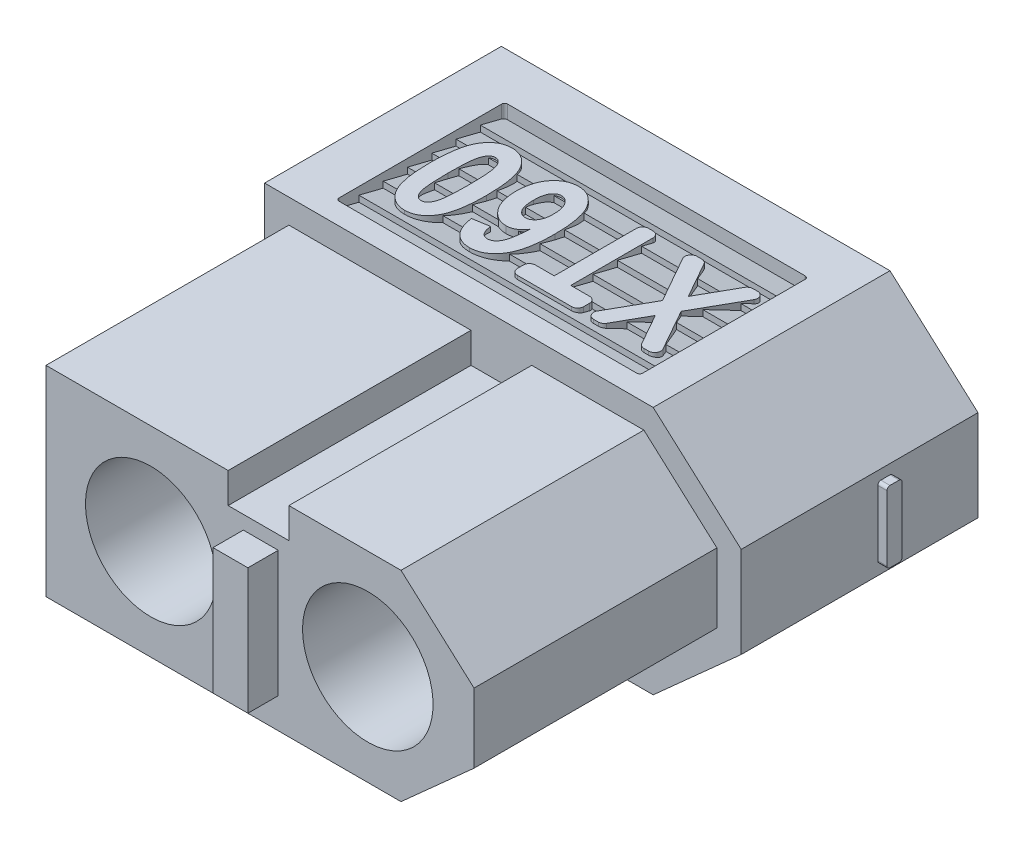
from build123d import *

# Parameters (mm, degrees)
RESSALTO_EXTRUS_O1_DEPTH  = 15.8
CORTE_EXTRUS_O1_DEPTH     = 8
ESBO_O5_R                 = 3
CORTE_EXTRUS_O3_DEPTH     = 2
ESBO_O6_R                 = 2.15
CORTE_EXTRUS_O4_DEPTH     = 14.8
RESSALTO_EXTRUS_O3_DEPTH  = 0.3
RESSALTO_EXTRUS_O4_DEPTH  = 0.3
CORTE_EXTRUS_O5_DEPTH     = 0.75
RESSALTO_EXTRUS_O7_DEPTH  = 10
RESSALTO_EXTRUS_O8_DEPTH  = 0.3
RESSALTO_EXTRUS_O9_DEPTH  = 0.3
ESBO_O13_W                = 1.15
ESBO_O13_H                = 4.15
RESSALTO_EXTRUS_O10_DEPTH = 1


with BuildPart() as part:
    # Esboço1 → Ressalto-extrusão1 (new body)
    with BuildSketch(Plane.XY):
        Polygon((0, 0), (12.8, 0), (15.7, 2.6), (15.7, 5.6), (12.8, 8.2), (0, 8.2), align=None)
    extrude(amount=RESSALTO_EXTRUS_O1_DEPTH)

    # Esboço2 → Corte-extrusão1 (cut)
    with BuildSketch(Plane.XY.offset(15.8)):
        Polygon((0, 8.2), (0, 0), (12.8, 0), (15.7, 2.6), (15.7, 5.6), (12.8, 8.2), align=None)
        Polygon((0.8, 7.4), (0.8, 0.8), (12.49388664, 0.8), (14.9, 2.957205081), (14.9, 5.242794919), (12.49388664, 7.4), (8.8, 7.4), (8.8, 6.4), (6.8, 6.4), (6.8, 7.4), align=None, mode=Mode.SUBTRACT)
    extrude(amount=-CORTE_EXTRUS_O1_DEPTH, mode=Mode.SUBTRACT)

    # Esboço5 → Corte-extrusão3 (cut)
    with BuildSketch(Plane(origin=(0, 0, 0), x_dir=(-1, 0, 0), z_dir=(0, 0, -1))):
        with Locations((-11.4, 4.1)):
            Circle(ESBO_O5_R)
        with Locations((-4.25, 4.1)):
            Circle(ESBO_O5_R)
    extrude(amount=-CORTE_EXTRUS_O3_DEPTH, mode=Mode.SUBTRACT)

    # Esboço6 → Corte-extrusão4 (cut, through all)
    with BuildSketch(Plane(origin=(0, 0, 2), x_dir=(-1, 0, 0), z_dir=(0, 0, -1))):
        with Locations((-11.4, 4.1)):
            Circle(ESBO_O6_R)
        with Locations((-4.25, 4.1)):
            Circle(ESBO_O6_R)
    extrude(amount=-CORTE_EXTRUS_O4_DEPTH, mode=Mode.SUBTRACT)

    # Esboço7 → Ressalto-extrusão3 (add)
    with BuildSketch(Plane.ZY):
        with BuildLine():
            Line((2.8, 4.35), (2.05, 4.35))
            ThreePointArc((2.05, 4.35), (1.979289322, 4.320710678), (1.95, 4.25))
            Line((1.95, 4.25), (1.95, 3.95))
            ThreePointArc((1.95, 3.95), (1.979289322, 3.879289322), (2.05, 3.85))
            Line((2.05, 3.85), (2.8, 3.85))
            ThreePointArc((2.8, 3.85), (2.870710678, 3.820710678), (2.9, 3.75))
            Line((2.9, 3.75), (2.9, 3))
            ThreePointArc((2.9, 3), (2.929289322, 2.929289322), (3, 2.9))
            Line((3, 2.9), (3.3, 2.9))
            ThreePointArc((3.3, 2.9), (3.370710678, 2.929289322), (3.4, 3))
            Line((3.4, 3), (3.4, 3.75))
            ThreePointArc((3.4, 3.75), (3.429289322, 3.820710678), (3.5, 3.85))
            Line((3.5, 3.85), (4.25, 3.85))
            ThreePointArc((4.25, 3.85), (4.320710678, 3.879289322), (4.35, 3.95))
            Line((4.35, 3.95), (4.35, 4.25))
            ThreePointArc((4.35, 4.25), (4.320710678, 4.320710678), (4.25, 4.35))
            Line((4.25, 4.35), (3.5, 4.35))
            ThreePointArc((3.5, 4.35), (3.429289322, 4.379289322), (3.4, 4.45))
            Line((3.4, 4.45), (3.4, 5.2))
            ThreePointArc((3.4, 5.2), (3.370710678, 5.270710678), (3.3, 5.3))
            Line((3.3, 5.3), (3, 5.3))
            ThreePointArc((3, 5.3), (2.929289322, 5.270710678), (2.9, 5.2))
            Line((2.9, 5.2), (2.9, 4.45))
            ThreePointArc((2.9, 4.45), (2.870710678, 4.379289322), (2.8, 4.35))
        make_face()
    extrude(amount=RESSALTO_EXTRUS_O3_DEPTH)

    # Esboço8 → Ressalto-extrusão4 (add)
    with BuildSketch(Plane(origin=(15.7, 0, 0), x_dir=(0, 0, -1), z_dir=(1, 0, 0))):
        with BuildLine():
            Line((-3.2, 2.925), (-2.9, 2.925))
            ThreePointArc((-2.9, 2.925), (-2.829289322, 2.954289322), (-2.8, 3.025))
            Line((-2.8, 3.025), (-2.8, 5.175))
            ThreePointArc((-2.8, 5.175), (-2.829289322, 5.245710678), (-2.9, 5.275))
            Line((-2.9, 5.275), (-3.2, 5.275))
            ThreePointArc((-3.2, 5.275), (-3.270710678, 5.245710678), (-3.3, 5.175))
            Line((-3.3, 5.175), (-3.3, 3.025))
            ThreePointArc((-3.3, 3.025), (-3.270710678, 2.954289322), (-3.2, 2.925))
        make_face()
    extrude(amount=RESSALTO_EXTRUS_O4_DEPTH)

    # Esboço9 → Corte-extrusão5 (cut)
    with BuildSketch(Plane.XZ):
        with BuildLine():
            Line((1.75, 7.093123445), (11.55, 7.093123445))
            ThreePointArc((11.55, 7.093123445), (11.620710678, 7.063834123), (11.65, 6.993123445))
            Line((11.65, 6.993123445), (11.65, 1.643123445))
            ThreePointArc((11.65, 1.643123445), (11.620710678, 1.572412766), (11.55, 1.543123445))
            Line((11.55, 1.543123445), (1.75, 1.543123445))
            ThreePointArc((1.75, 1.543123445), (1.679289322, 1.572412766), (1.65, 1.643123445))
            Line((1.65, 1.643123445), (1.65, 6.993123445))
            ThreePointArc((1.65, 6.993123445), (1.679289322, 7.063834123), (1.75, 7.093123445))
        make_face()
    corte_extrus_o5 = extrude(amount=-CORTE_EXTRUS_O5_DEPTH, mode=Mode.SUBTRACT)

    # Esboço10 → Ressalto-extrusão7 (add)
    with BuildSketch(Plane(origin=(1.65, 0, 0), x_dir=(0, 0, -1), z_dir=(1, 0, 0))):
        Polygon((-3.143123445, 0.45), (-3.143123445, 0.25), (-2.343123445, 0.45), (-2.343123445, 0.25), (-1.543123445, 0.45), (-1.543123445, 0.75), (-7.143123445, 0.75), (-7.143123445, 0.45), (-7.143123445, 0.25), (-6.343123445, 0.45), (-6.343123445, 0.25), (-5.543123445, 0.45), (-5.543123445, 0.25), (-4.743123445, 0.45), (-4.743123445, 0.25), (-3.943123445, 0.45), (-3.943123445, 0.25), align=None)
    ressalto_extrus_o7 = extrude(amount=RESSALTO_EXTRUS_O7_DEPTH)

    # Espelhar1: Corte-extrusão5, Ressalto-extrusão7 across plane
    add(corte_extrus_o5.mirror(Plane.ZX.offset(4.1)), mode=Mode.SUBTRACT)
    add(ressalto_extrus_o7.mirror(Plane.ZX.offset(4.1)))

    # Esboço11 → Ressalto-extrusão8 (add)
    with BuildSketch(Plane(origin=(0, 0.5, 0), x_dir=(-1, 0, 0), z_dir=(0, -1, 0))):
        with BuildLine():
            Line((-2.594171468, -5.543123445), (-2.816677367, -5.543123445))
            ThreePointArc((-2.816677367, -5.543123445), (-2.931584034, -5.489541586), (-2.96439853, -5.367076218))
            Line((-2.96439853, -5.367076218), (-2.475213344, -2.592769164))
            ThreePointArc((-2.475213344, -2.592769164), (-2.50802784, -2.470303795), (-2.622934507, -2.416721937))
            Line((-2.622934507, -2.416721937), (-2.922945856, -2.416721937))
            ThreePointArc((-2.922945856, -2.416721937), (-3.019363998, -2.45181527), (-3.070667019, -2.54067471))
            Line((-3.070667019, -2.54067471), (-3.578223521, -5.419170671))
            ThreePointArc((-3.578223521, -5.419170671), (-3.629526543, -5.508030111), (-3.725944684, -5.543123445))
            Line((-3.725944684, -5.543123445), (-4.285644183, -5.543123445))
            ThreePointArc((-4.285644183, -5.543123445), (-4.3917102, -5.587057427), (-4.435644183, -5.693123445))
            Line((-4.435644183, -5.693123445), (-4.435644183, -5.993134794))
            ThreePointArc((-4.435644183, -5.993134794), (-4.3917102, -6.099200812), (-4.285644183, -6.143134794))
            Line((-4.285644183, -6.143134794), (-2.594171468, -6.143134794))
            ThreePointArc((-2.594171468, -6.143134794), (-2.48810545, -6.099200812), (-2.444171468, -5.993134794))
            Line((-2.444171468, -5.993134794), (-2.444171468, -5.693123445))
            ThreePointArc((-2.444171468, -5.693123445), (-2.48810545, -5.587057427), (-2.594171468, -5.543123445))
        make_face()
        with BuildLine():
            Line((-7.312799939, -6.143134794), (-5.987200061, -6.143134794))
            ThreePointArc((-5.987200061, -6.143134794), (-5.912200061, -6.123038605), (-5.85729625, -6.068134794))
            Line((-5.85729625, -6.068134794), (-5.828687438, -6.018582878))
            ThreePointArc((-5.828687438, -6.018582878), (-5.681353004, -5.702623165), (-5.591122739, -5.365879233))
            Line((-5.591122739, -5.365879233), (-5.150689111, -2.868056003))
            ThreePointArc((-5.150689111, -2.868056003), (-5.158867923, -2.786982124), (-5.208226408, -2.722146896))
            Line((-5.208226408, -2.722146896), (-5.574105578, -2.446860057))
            ThreePointArc((-5.574105578, -2.446860057), (-5.616746211, -2.424455845), (-5.664289444, -2.416721937))
            Line((-5.664289444, -2.416721937), (-6.747162349, -2.416721937))
            ThreePointArc((-6.747162349, -2.416721937), (-6.822162349, -2.436818126), (-6.877066159, -2.491721937))
            Line((-6.877066159, -2.491721937), (-7.246378339, -3.131389396))
            ThreePointArc((-7.246378339, -3.131389396), (-7.254434815, -3.146865743), (-7.261111782, -3.162985367))
            Line((-7.261111782, -3.162985367), (-7.486707327, -3.782804031))
            ThreePointArc((-7.486707327, -3.782804031), (-7.491953968, -3.799444251), (-7.495730353, -3.816478424))
            Line((-7.495730353, -3.816478424), (-7.600238849, -4.409175555))
            ThreePointArc((-7.600238849, -4.409175555), (-7.567424352, -4.531640924), (-7.452517686, -4.585222782))
            Line((-7.452517686, -4.585222782), (-6.814596908, -4.585222782))
            ThreePointArc((-6.814596908, -4.585222782), (-6.708530891, -4.541288799), (-6.664596908, -4.435222782))
            Line((-6.664596908, -4.435222782), (-6.664596908, -4.135222782))
            ThreePointArc((-6.664596908, -4.135222782), (-6.688852376, -4.053440677), (-6.75377441, -3.998107415))
            ThreePointArc((-6.75377441, -3.998107415), (-6.813094, -3.957706293), (-6.85433126, -3.898964887))
            Line((-6.85433126, -3.898964887), (-6.980409874, -3.625265301))
            ThreePointArc((-6.980409874, -3.625265301), (-6.998662224, -3.535451732), (-6.974936214, -3.446926583))
            Line((-6.974936214, -3.446926583), (-6.800387282, -3.122061179))
            ThreePointArc((-6.800387282, -3.122061179), (-6.726842336, -3.045065082), (-6.624207428, -3.016721937))
            Line((-6.624207428, -3.016721937), (-5.905334252, -3.016721937))
            ThreePointArc((-5.905334252, -3.016721937), (-5.828729808, -3.052443176), (-5.806853477, -3.134086755))
            Line((-5.806853477, -3.134086755), (-6.209775425, -5.419170671))
            ThreePointArc((-6.209775425, -5.419170671), (-6.261078446, -5.508030111), (-6.357496588, -5.543123445))
            Line((-6.357496588, -5.543123445), (-7.076369764, -5.543123445))
            ThreePointArc((-7.076369764, -5.543123445), (-7.152974208, -5.507402206), (-7.174850539, -5.425758627))
            Line((-7.174850539, -5.425758627), (-7.151219061, -5.291737858))
            ThreePointArc((-7.151219061, -5.291737858), (-7.184033558, -5.16927249), (-7.298940224, -5.115690631))
            Line((-7.298940224, -5.115690631), (-7.598951574, -5.115690631))
            ThreePointArc((-7.598951574, -5.115690631), (-7.695369716, -5.150783965), (-7.746672737, -5.239643405))
            Line((-7.746672737, -5.239643405), (-7.826400273, -5.691800728))
            ThreePointArc((-7.826400273, -5.691800728), (-7.81822146, -5.772874607), (-7.768862976, -5.837709835))
            Line((-7.768862976, -5.837709835), (-7.402983805, -6.112996674))
            ThreePointArc((-7.402983805, -6.112996674), (-7.360343172, -6.135400887), (-7.312799939, -6.143134794))
        make_face()
        with BuildLine():
            Line((-8.976581944, -6.143134794), (-9.276593294, -6.143134794))
            ThreePointArc((-9.276593294, -6.143134794), (-9.383119611, -6.098738505), (-9.426587619, -5.991830045))
            Line((-9.426587619, -5.991830045), (-9.419815007, -5.213249059))
            ThreePointArc((-9.419815007, -5.213249059), (-9.453507368, -5.165547636), (-9.509444688, -5.182329089))
            Line((-9.509444688, -5.182329089), (-10.203473932, -6.084589954))
            ThreePointArc((-10.203473932, -6.084589954), (-10.256105062, -6.127704988), (-10.32236865, -6.143134794))
            Line((-10.32236865, -6.143134794), (-10.62238, -6.143134794))
            ThreePointArc((-10.62238, -6.143134794), (-10.756950193, -6.059398382), (-10.741274717, -5.901679635))
            Line((-10.741274717, -5.901679635), (-9.415426652, -4.178033505))
            Line((-9.415426652, -4.178033505), (-9.12671612, -2.54067471))
            ThreePointArc((-9.12671612, -2.54067471), (-9.075413098, -2.45181527), (-8.978994957, -2.416721937))
            Line((-8.978994957, -2.416721937), (-8.678983607, -2.416721937))
            ThreePointArc((-8.678983607, -2.416721937), (-8.56407694, -2.470303795), (-8.531262444, -2.592769164))
            Line((-8.531262444, -2.592769164), (-8.810787319, -4.178033505))
            Line((-8.810787319, -4.178033505), (-8.826587619, -5.994439544))
            ThreePointArc((-8.826587619, -5.994439544), (-8.870978233, -6.099661111), (-8.976581944, -6.143134794))
        make_face()
    extrude(amount=RESSALTO_EXTRUS_O8_DEPTH)

    # Esboço12 → Ressalto-extrusão9 (add)
    with BuildSketch(Plane(origin=(0, 7.7, 0), x_dir=(1, 0, 0), z_dir=(0, 1, 0))):
        with BuildLine():
            Line((11.185044584, -2.866454717), (10.320104725, -4.398379126))
            Line((10.320104725, -4.398379126), (11.094198639, -5.769814539))
            ThreePointArc((11.094198639, -5.769814539), (11.092744365, -5.968965447), (10.920028151, -6.068123445))
            Line((10.920028151, -6.068123445), (10.7649422, -6.068123445))
            ThreePointArc((10.7649422, -6.068123445), (10.664138477, -6.040862003), (10.590815302, -5.966509539))
            Line((10.590815302, -5.966509539), (10.012576316, -4.943123445))
            Line((10.012576316, -4.943123445), (9.435030455, -5.966426179))
            ThreePointArc((9.435030455, -5.966426179), (9.361701545, -6.040837872), (9.260856483, -6.068123445))
            Line((9.260856483, -6.068123445), (9.105124481, -6.068123445))
            ThreePointArc((9.105124481, -6.068123445), (8.932408267, -5.968965447), (8.930953993, -5.769814539))
            Line((8.930953993, -5.769814539), (9.705047907, -4.398379126))
            Line((9.705047907, -4.398379126), (8.840108048, -2.866454717))
            ThreePointArc((8.840108048, -2.866454717), (8.841543221, -2.667292533), (9.01426591, -2.568123445))
            Line((9.01426591, -2.568123445), (9.169940798, -2.568123445))
            ThreePointArc((9.169940798, -2.568123445), (9.270790107, -2.595411497), (9.344119604, -2.669829276))
            Line((9.344119604, -2.669829276), (10.012576316, -3.854345035))
            Line((10.012576316, -3.854345035), (10.681728288, -2.669756355))
            ThreePointArc((10.681728288, -2.669756355), (10.755052773, -2.595390388), (10.855865922, -2.568123445))
            Line((10.855865922, -2.568123445), (11.010886722, -2.568123445))
            ThreePointArc((11.010886722, -2.568123445), (11.183609411, -2.667292533), (11.185044584, -2.866454717))
        make_face()
        with BuildLine():
            Line((7.762576316, -2.768123445), (7.762576316, -5.477214354))
            Line((7.762576316, -5.477214354), (8.380758134, -5.477214354))
            ThreePointArc((8.380758134, -5.477214354), (8.522179491, -5.535792997), (8.580758134, -5.677214354))
            Line((8.580758134, -5.677214354), (8.580758134, -5.868123445))
            ThreePointArc((8.580758134, -5.868123445), (8.522179491, -6.009544801), (8.380758134, -6.068123445))
            Line((8.380758134, -6.068123445), (6.598939953, -6.068123445))
            ThreePointArc((6.598939953, -6.068123445), (6.457518596, -6.009544801), (6.398939953, -5.868123445))
            Line((6.398939953, -5.868123445), (6.398939953, -5.677214354))
            ThreePointArc((6.398939953, -5.677214354), (6.457518596, -5.535792997), (6.598939953, -5.477214354))
            Line((6.598939953, -5.477214354), (7.217121771, -5.477214354))
            Line((7.217121771, -5.477214354), (7.217121771, -2.768123445))
            ThreePointArc((7.217121771, -2.768123445), (7.275700414, -2.626702088), (7.417121771, -2.568123445))
            Line((7.417121771, -2.568123445), (7.562576316, -2.568123445))
            ThreePointArc((7.562576316, -2.568123445), (7.703997672, -2.626702088), (7.762576316, -2.768123445))
        make_face()
        with BuildLine():
            Line((4.217121771, -5.204487081), (4.762576316, -5.11357799))
            add(Edge.make_bspline(
                [(4.762576316, -5.11357799), (4.76820949, -5.173924633), (4.781337444, -5.259439061), (4.819168165, -5.361191101), (4.853361229, -5.419789109), (4.894424887, -5.466597978), (4.961777465, -5.510957772), (5.022038471, -5.523265851), (5.062292225, -5.522668899)],
                knots=[0, 0, 0, 0, 0.323351038, 0.457031878, 0.575725889, 0.682827962, 0.785621923, 1, 1, 1, 1], degree=3))
            add(Edge.make_bspline(
                [(5.062292225, -5.522668899), (5.090005536, -5.523271256), (5.131240753, -5.516505903), (5.183240033, -5.496464747), (5.220091612, -5.475090137), (5.254809063, -5.44738128), (5.287295538, -5.413652015), (5.318784831, -5.374418203), (5.348496948, -5.327992624), (5.375862324, -5.27190132), (5.400526587, -5.204375405), (5.42080653, -5.124170881), (5.441377932, -5.032489264), (5.456741962, -4.927718403), (5.47688134, -4.763925871), (5.485298827, -4.634283794), (5.489849043, -4.543975717)],
                knots=[0, 0, 0, 0, 0.07110629, 0.106432223, 0.14303469, 0.180361233, 0.220458154, 0.263402163, 0.309743564, 0.362096385, 0.423824058, 0.494518004, 0.575001043, 0.665717727, 0.767054977, 1, 1, 1, 1], degree=3))
            add(Edge.make_bspline(
                [(5.489849043, -4.543975717), (5.458325439, -4.59029492), (5.407025482, -4.654615722), (5.327609617, -4.725483765), (5.267100836, -4.768088661), (5.202789438, -4.800226136), (5.112590312, -4.832606749), (5.040111771, -4.83988466), (4.991979725, -4.840850717)],
                knots=[0, 0, 0, 0, 0.277998008, 0.405177954, 0.526602292, 0.643637452, 0.760548992, 1, 1, 1, 1], degree=3))
            add(Edge.make_bspline(
                [(4.991979725, -4.840850717), (4.938397795, -4.840049228), (4.857644594, -4.832427325), (4.755876709, -4.798007625), (4.682335645, -4.763632003), (4.610596897, -4.720231075), (4.542640345, -4.665558625), (4.476889163, -4.601961344), (4.414752476, -4.529006286), (4.357734038, -4.448067208), (4.307371702, -4.360004902), (4.266071161, -4.265189584), (4.230469873, -4.164568314), (4.205010426, -4.057053869), (4.1786726, -3.902079336), (4.170937798, -3.781658743), (4.171667225, -3.69951549)],
                knots=[0, 0, 0, 0, 0.103373273, 0.154207333, 0.205955138, 0.259297376, 0.315055498, 0.373346508, 0.435038939, 0.499094576, 0.56354236, 0.62980043, 0.697776404, 0.768573701, 0.842016383, 1, 1, 1, 1], degree=3))
            add(Edge.make_bspline(
                [(4.171667225, -3.69951549), (4.17185896, -3.612421658), (4.179060828, -3.485146498), (4.205900348, -3.321369203), (4.234396433, -3.20963002), (4.2696034, -3.104366118), (4.314707671, -3.007473367), (4.366288245, -2.916922605), (4.426957594, -2.835664661), (4.492885026, -2.762488286), (4.56321129, -2.698010574), (4.638016826, -2.644053991), (4.716117978, -2.599205297), (4.798442704, -2.564863658), (4.914867128, -2.532610579), (5.005897079, -2.522349793), (5.067263816, -2.522668899)],
                knots=[0, 0, 0, 0, 0.157846943, 0.230497149, 0.300424491, 0.366636184, 0.431332033, 0.493808926, 0.555163499, 0.614703094, 0.672106668, 0.727718583, 0.781520235, 0.834985538, 0.88891022, 1, 1, 1, 1], degree=3))
            add(Edge.make_bspline(
                [(5.067263816, -2.522668899), (5.134776318, -2.522388948), (5.235013241, -2.535219464), (5.362092148, -2.577511404), (5.451550186, -2.622540527), (5.536655096, -2.680446511), (5.616741921, -2.751072456), (5.692332527, -2.834441462), (5.763971124, -2.930110778), (5.82918472, -3.04081959), (5.883929661, -3.168816952), (5.931571611, -3.312472802), (5.969029009, -3.473320865), (5.999665981, -3.650168244), (6.028262771, -3.919162037), (6.035311504, -4.129776969), (6.035303589, -4.275509808)],
                knots=[0, 0, 0, 0, 0.090693495, 0.134685131, 0.179530034, 0.224912922, 0.272737739, 0.322760271, 0.375986421, 0.433203955, 0.495069598, 0.562818628, 0.636478469, 0.716917714, 0.804030531, 1, 1, 1, 1], degree=3))
            add(Edge.make_bspline(
                [(6.035303589, -4.275509808), (6.035321208, -4.423581802), (6.028586042, -4.637939475), (5.997249035, -4.911199563), (5.966641992, -5.091655496), (5.926254815, -5.255456188), (5.877882298, -5.403133674), (5.820063121, -5.534267496), (5.751835344, -5.647887006), (5.677444095, -5.746891367), (5.597624044, -5.832519938), (5.513228762, -5.905957941), (5.422406745, -5.96445997), (5.327623343, -6.011484887), (5.191786058, -6.055622146), (5.084345761, -6.068641489), (5.011866089, -6.068123445)],
                knots=[0, 0, 0, 0, 0.192657569, 0.278521348, 0.357596923, 0.430563241, 0.497752602, 0.559502274, 0.616536619, 0.669746994, 0.720292489, 0.768554988, 0.814846956, 0.860430936, 0.905808517, 1, 1, 1, 1], degree=3))
            add(Edge.make_bspline(
                [(5.011866089, -6.068123445), (4.961903446, -6.06789345), (4.888028114, -6.061626473), (4.793001037, -6.039603881), (4.725795095, -6.016102048), (4.661944049, -5.985106158), (4.600204149, -5.948907027), (4.541772821, -5.905419857), (4.487247773, -5.854566598), (4.43554269, -5.798076733), (4.390262811, -5.733146732), (4.348758109, -5.662053174), (4.313065822, -5.583489418), (4.280538021, -5.498839828), (4.24537643, -5.372392174), (4.226035204, -5.273167916), (4.217121771, -5.204487081)],
                knots=[0, 0, 0, 0, 0.115543302, 0.170649433, 0.225187049, 0.279790566, 0.334525644, 0.390473716, 0.447810616, 0.506730268, 0.567186295, 0.630471054, 0.696846024, 0.766492743, 0.839958973, 1, 1, 1, 1], degree=3))
        make_face()
        with BuildLine():
            add(Edge.make_bspline(
                [(5.444394498, -3.721532535), (5.443413243, -3.671816504), (5.441774499, -3.598919405), (5.428964767, -3.50575196), (5.416513606, -3.442460626), (5.39901126, -3.384318695), (5.379738685, -3.329960639), (5.355461716, -3.280752232), (5.327421984, -3.236743151), (5.298038654, -3.197058094), (5.266817632, -3.162801594), (5.234319039, -3.134257306), (5.201874492, -3.109517602), (5.167408759, -3.090781113), (5.119948206, -3.073930539), (5.082776396, -3.068257967), (5.058030862, -3.068123445)],
                knots=[0, 0, 0, 0, 0.178482482, 0.260708928, 0.336947951, 0.40946762, 0.47821344, 0.543503214, 0.605672981, 0.665087478, 0.720355931, 0.771459165, 0.820010483, 0.866344773, 0.911449985, 1, 1, 1, 1], degree=3))
            add(Edge.make_bspline(
                [(5.058030862, -3.068123445), (5.011333584, -3.067304655), (4.939791649, -3.085797467), (4.86264655, -3.146956505), (4.819952016, -3.197224746), (4.79035383, -3.246363095), (4.770537869, -3.289704134), (4.754443985, -3.338919978), (4.740189246, -3.393143293), (4.729596718, -3.453239822), (4.72052411, -3.544234997), (4.716316659, -3.615360982), (4.717121771, -3.664714354)],
                knots=[0, 0, 0, 0, 0.182717956, 0.277311697, 0.381920987, 0.439334057, 0.501576805, 0.568145713, 0.64192066, 0.721049878, 0.806868135, 1, 1, 1, 1], degree=3))
            add(Edge.make_bspline(
                [(4.717121771, -3.664714354), (4.717023666, -3.715881874), (4.71928254, -3.790108644), (4.731260972, -3.884669406), (4.742289738, -3.947647624), (4.757256441, -4.005038937), (4.774726651, -4.057271853), (4.795918712, -4.103878339), (4.828454634, -4.156184323), (4.87337471, -4.211354153), (4.957448965, -4.275083227), (5.032786713, -4.296660278), (5.082888816, -4.295396172)],
                knots=[0, 0, 0, 0, 0.189207564, 0.273855027, 0.352111634, 0.425324443, 0.49283636, 0.555472207, 0.61399486, 0.72019415, 0.816437051, 1, 1, 1, 1], degree=3))
            add(Edge.make_bspline(
                [(5.082888816, -4.295396172), (5.131526314, -4.295488538), (5.205689597, -4.276323592), (5.287703716, -4.214653218), (5.333020871, -4.162954728), (5.365244164, -4.113471075), (5.386562707, -4.070535517), (5.404216359, -4.023081599), (5.419178051, -3.971365378), (5.430172085, -3.91499019), (5.442161504, -3.831586596), (5.444525217, -3.766315864), (5.444394498, -3.721532535)],
                knots=[0, 0, 0, 0, 0.192976457, 0.293260508, 0.40387877, 0.464412825, 0.527516319, 0.593906739, 0.665362139, 0.741185596, 0.82193725, 1, 1, 1, 1], degree=3))
        make_face(mode=Mode.SUBTRACT)
        with BuildLine():
            add(Edge.make_bspline(
                [(2.877633134, -6.068123445), (2.810730433, -6.067849084), (2.711314347, -6.056349671), (2.585994956, -6.0147115), (2.498310016, -5.971140602), (2.415902857, -5.914953241), (2.338568607, -5.846563404), (2.266246061, -5.765980633), (2.198470254, -5.672487326), (2.137564732, -5.563141791), (2.085547014, -5.43597675), (2.041861983, -5.290553015), (2.006259497, -5.126888157), (1.978040904, -4.944750096), (1.951290686, -4.665360773), (1.9446089, -4.446077253), (1.944394498, -4.293975717)],
                knots=[0, 0, 0, 0, 0.089720065, 0.13287086, 0.176439702, 0.220535808, 0.266180481, 0.314487638, 0.365396204, 0.420661105, 0.481833882, 0.5491908, 0.623951051, 0.706174952, 0.796103949, 1, 1, 1, 1], degree=3))
            add(Edge.make_bspline(
                [(1.944394498, -4.293975717), (1.944638719, -4.142353226), (1.951233344, -3.923761612), (1.97812578, -3.645109231), (2.006115325, -3.463394365), (2.042144964, -3.299848), (2.08521413, -3.154455192), (2.137775908, -3.027506965), (2.19840458, -2.918257183), (2.26630614, -2.825073804), (2.337841143, -2.744006751), (2.415214295, -2.675842312), (2.497463758, -2.619864691), (2.584721063, -2.575889294), (2.709503059, -2.534751072), (2.808285478, -2.522615935), (2.874792225, -2.522668899)],
                knots=[0, 0, 0, 0, 0.20374449, 0.293570465, 0.37598958, 0.450616808, 0.518437924, 0.579462338, 0.634858447, 0.685887879, 0.734097166, 0.779850207, 0.824051004, 0.867438546, 0.910691788, 1, 1, 1, 1], degree=3))
            add(Edge.make_bspline(
                [(2.874792225, -2.522668899), (2.941484266, -2.523710824), (3.041281588, -2.533299712), (3.166214895, -2.575602655), (3.254335121, -2.618030045), (3.336271187, -2.674506287), (3.413868558, -2.742018188), (3.486229751, -2.821916845), (3.541301575, -2.897840806), (3.58269805, -2.96498955), (3.611578144, -3.021150661), (3.638494695, -3.081976307), (3.664404568, -3.147121215), (3.686601305, -3.217861571), (3.708035904, -3.292850452), (3.727138607, -3.372484959), (3.744019269, -3.456881892), (3.759963805, -3.545815866), (3.772136852, -3.639993555), (3.784042777, -3.73839755), (3.79197113, -3.841982247), (3.799364724, -3.949918137), (3.805668325, -4.103578693), (3.808979936, -4.221020489), (3.808030862, -4.30107799)],
                knots=[0, 0, 0, 0, 0.089417833, 0.132451122, 0.17576164, 0.219737665, 0.265049642, 0.312990798, 0.36350462, 0.390208605, 0.418376443, 0.447842402, 0.479107586, 0.512034425, 0.546898156, 0.583358489, 0.621466834, 0.661945644, 0.704106633, 0.74838679, 0.794432191, 0.842955807, 0.893007524, 1, 1, 1, 1], degree=3))
            add(Edge.make_bspline(
                [(3.808030862, -4.30107799), (3.807817856, -4.452232991), (3.801141288, -4.670100701), (3.77439671, -4.947596735), (3.746123955, -5.128547937), (3.710429855, -5.2914618), (3.667063402, -5.436528845), (3.614663538, -5.563289526), (3.554017471, -5.672534186), (3.486120024, -5.765718776), (3.414584018, -5.846785534), (3.337211115, -5.914950047), (3.254961588, -5.970927649), (3.1677043, -6.014903051), (3.042922298, -6.056041271), (2.944139883, -6.068176409), (2.877633134, -6.068123445)],
                knots=[0, 0, 0, 0, 0.203492419, 0.293170916, 0.375115996, 0.449884158, 0.517528497, 0.578668156, 0.63416888, 0.68529468, 0.73359501, 0.779434455, 0.823718726, 0.867188205, 0.91052313, 1, 1, 1, 1], degree=3))
        make_face()
        with BuildLine():
            add(Edge.make_bspline(
                [(2.87621268, -5.522668899), (2.901364042, -5.522485609), (2.939097549, -5.515660071), (2.985335807, -5.493598364), (3.017683977, -5.469594025), (3.047216064, -5.438647253), (3.075339951, -5.401740483), (3.101506106, -5.358172557), (3.12641129, -5.306134624), (3.149342747, -5.241231001), (3.166151656, -5.159207953), (3.182876915, -5.059800058), (3.194653181, -4.94184505), (3.205633471, -4.805970595), (3.214801743, -4.587864315), (3.217213683, -4.415214807), (3.217121771, -4.293975717)],
                knots=[0, 0, 0, 0, 0.054971734, 0.082543038, 0.111449392, 0.142585763, 0.175843141, 0.212799818, 0.253577709, 0.301907888, 0.362981983, 0.436474838, 0.522452758, 0.62221279, 0.734739184, 1, 1, 1, 1], degree=3))
            add(Edge.make_bspline(
                [(3.217121771, -4.293975717), (3.21723583, -4.172972758), (3.214784306, -4.000561073), (3.205636937, -3.782690927), (3.1946447, -3.646816985), (3.182924905, -3.529093066), (3.166201502, -3.430144515), (3.149194996, -3.348656915), (3.126599369, -3.284100945), (3.10136876, -3.232430205), (3.075070877, -3.189035557), (3.047700598, -3.151480559), (3.017409268, -3.12122859), (2.985369959, -3.097161665), (2.939075289, -3.075153336), (2.90137521, -3.068296168), (2.87621268, -3.068123445)],
                knots=[0, 0, 0, 0, 0.265261864, 0.37800881, 0.477964371, 0.564110808, 0.637235602, 0.697923266, 0.746348172, 0.786738496, 0.823767607, 0.857503931, 0.888332168, 0.917295178, 0.944920522, 1, 1, 1, 1], degree=3))
            add(Edge.make_bspline(
                [(2.87621268, -3.068123445), (2.850853743, -3.06826339), (2.812769868, -3.074946916), (2.766299747, -3.09740445), (2.733342983, -3.120920239), (2.703673517, -3.152483033), (2.674972494, -3.18923417), (2.649713603, -3.233592599), (2.624355717, -3.285184399), (2.602790537, -3.350256609), (2.58540287, -3.431527346), (2.568868237, -3.530529492), (2.556880667, -3.647964997), (2.547054602, -3.783677003), (2.537421398, -4.001016412), (2.53533009, -4.17322022), (2.535303589, -4.293975717)],
                knots=[0, 0, 0, 0, 0.055564279, 0.083173738, 0.112539997, 0.143719458, 0.177750147, 0.214491628, 0.255325951, 0.303553145, 0.364205914, 0.437288662, 0.523385566, 0.622727249, 0.735409366, 1, 1, 1, 1], degree=3))
            add(Edge.make_bspline(
                [(2.535303589, -4.293975717), (2.535358365, -4.415203081), (2.537372615, -4.587884379), (2.547093196, -4.805928634), (2.55683239, -4.941884397), (2.568925317, -5.059781156), (2.58543415, -5.159253805), (2.602692398, -5.241029088), (2.624346813, -5.306328369), (2.64975742, -5.357875374), (2.674734641, -5.402217911), (2.703911573, -5.438360922), (2.733316363, -5.469892787), (2.766306204, -5.493382877), (2.812765639, -5.515848713), (2.850855904, -5.522527274), (2.87621268, -5.522668899)],
                knots=[0, 0, 0, 0, 0.265054696, 0.377493652, 0.477137187, 0.563048299, 0.636484046, 0.697510684, 0.745633806, 0.786380011, 0.823042207, 0.85659068, 0.887702857, 0.917005746, 0.944555625, 1, 1, 1, 1], degree=3))
        make_face(mode=Mode.SUBTRACT)
    extrude(amount=RESSALTO_EXTRUS_O9_DEPTH)

    # Esboço13 → Ressalto-extrusão10 (add)
    with BuildSketch(Plane.XY.offset(15.8)):
        with Locations((7.875, 3.875)):
            Rectangle(ESBO_O13_W, ESBO_O13_H)
    extrude(amount=RESSALTO_EXTRUS_O10_DEPTH)


solid = part.part
